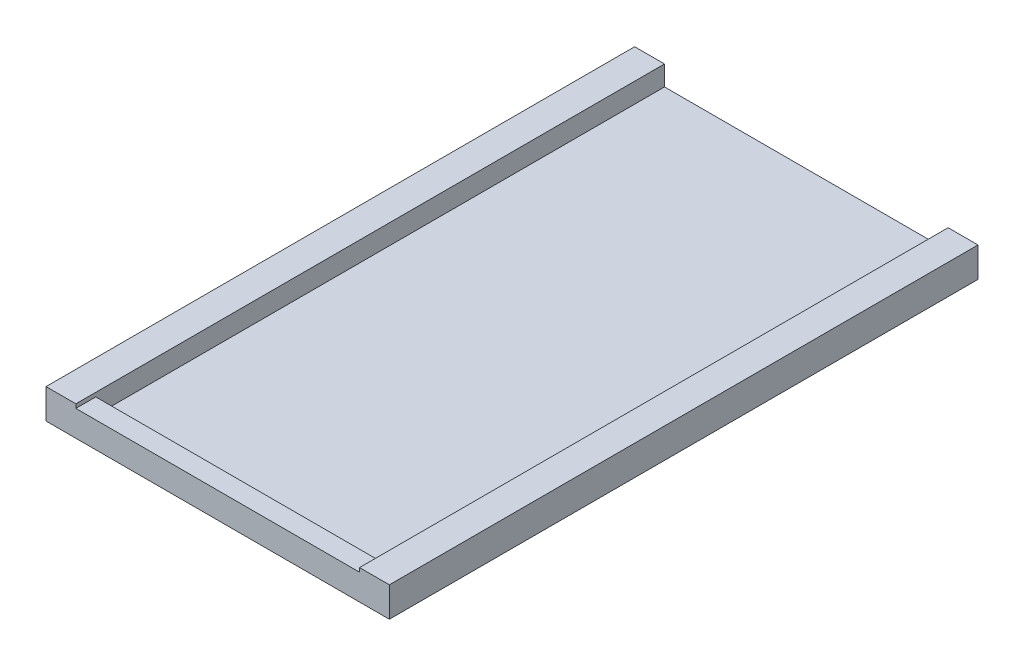
from build123d import *

# Parameters (mm, degrees)
BOSS_EXTRUDE1_DEPTH = 2.6
SKETCH3_W           = 3
SKETCH3_H           = 59.15
BOSS_EXTRUDE2_DEPTH = 0.4
SKETCH5_W           = 28.5
SKETCH5_H           = 1
BOSS_EXTRUDE3_DEPTH = 57.15


with BuildPart() as part:
    # Sketch1 → Boss-Extrude1 (new body)
    with BuildSketch(Plane(origin=(0, 0, 0), x_dir=(1, 0, 0), z_dir=(0, 1, 0))):
        Polygon((0, 0), (17.25, 0), (17.25, 59.15), (14.25, 59.15), (14.25, 2), (0, 2), align=None)
    boss_extrude1 = extrude(amount=BOSS_EXTRUDE1_DEPTH)

    # Sketch3 → Boss-Extrude2 (add)
    with BuildSketch(Plane(origin=(0, 2.6, 0), x_dir=(1, 0, 0), z_dir=(0, 1, 0))):
        with Locations((15.75, 29.575)):
            Rectangle(SKETCH3_W, SKETCH3_H)
    boss_extrude2 = extrude(amount=BOSS_EXTRUDE2_DEPTH)

    # Mirror2: Boss-Extrude1, Boss-Extrude2 across plane
    add(boss_extrude1.mirror(Plane(origin=(0, 0, 0), x_dir=(0, 0, 1), z_dir=(1, 0, 0))))
    add(boss_extrude2.mirror(Plane(origin=(0, 0, 0), x_dir=(0, 0, 1), z_dir=(1, 0, 0))))

    # Sketch5 → Boss-Extrude3 (add, through all)
    with BuildSketch(Plane(origin=(0, 0, -2), x_dir=(-1, 0, 0), z_dir=(0, 0, -1))):
        with Locations((0, 0.5)):
            Rectangle(SKETCH5_W, SKETCH5_H)
    extrude(amount=BOSS_EXTRUDE3_DEPTH)


solid = part.part
